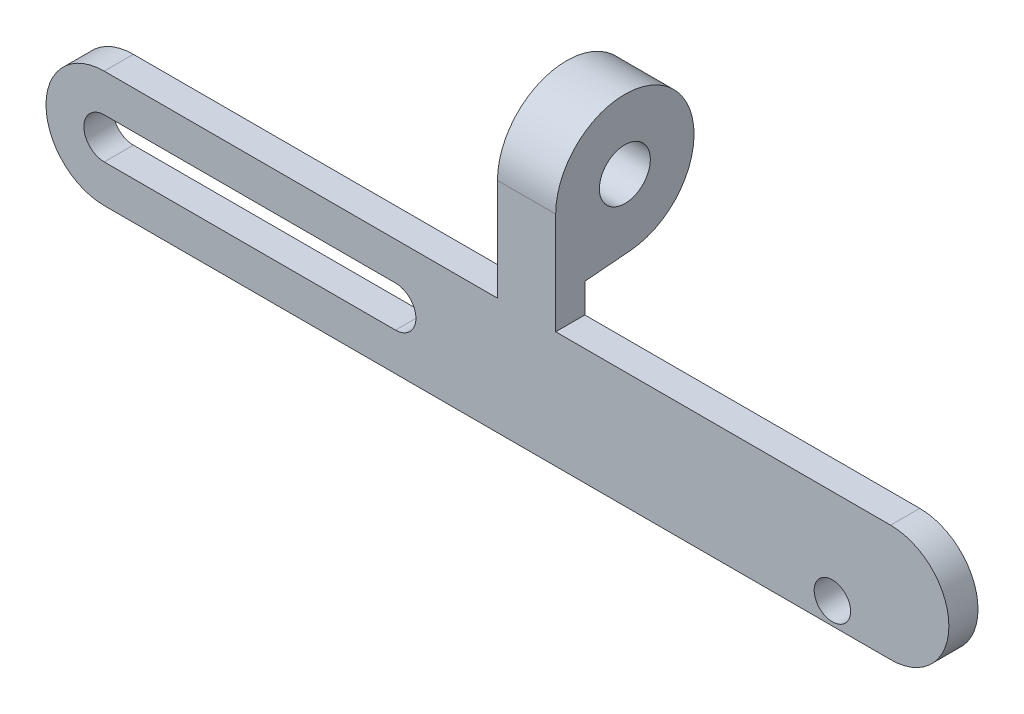
from build123d import *

# Parameters (mm, degrees)
ESBO_O1_R                = 1.25
RESSALTO_EXTRUS_O1_DEPTH = 2
ESBO_O2_R                = 0.75
RESSALTO_EXTRUS_O2_DEPTH = 5
ESBO_O3_R                = 1.75
RESSALTO_EXTRUS_O3_DEPTH = 4


with BuildPart() as part:
    # Esboço1 → Ressalto-extrusão1 (new body)
    with BuildSketch(Plane.XY):
        with BuildLine():
            Line((-27, 4), (27, 4))
            ThreePointArc((27, 4), (31, 0), (27, -4))
            Line((27, -4), (-27, -4))
            ThreePointArc((-27, -4), (-31, 0), (-27, 4))
        make_face()
        with Locations((23, -2.5)):
            Circle(ESBO_O1_R, mode=Mode.SUBTRACT)
        with BuildLine():
            Line((-27, 1.4), (-7, 1.4))
            ThreePointArc((-7, 1.4), (-5.6, 0), (-7, -1.4))
            Line((-7, -1.4), (-27, -1.4))
            ThreePointArc((-27, -1.4), (-28.4, 0), (-27, 1.4))
        make_face(mode=Mode.SUBTRACT)
    extrude(amount=RESSALTO_EXTRUS_O1_DEPTH)

    # Esboço2 → Ressalto-extrusão2 (add)
    with BuildSketch(Plane.XY.offset(2)):
        with Locations((27, -2.4)):
            Circle(ESBO_O2_R)
    extrude(amount=-RESSALTO_EXTRUS_O2_DEPTH)

    # Esboço3 → Ressalto-extrusão3 (add)
    with BuildSketch(Plane(origin=(0, 0, 0), x_dir=(0, 0, -1), z_dir=(1, 0, 0))):
        with BuildLine():
            Line((-2, 4), (-2, 11))
            ThreePointArc((-2, 11), (5.96386061, 14.497656355), (3.150989464, 6.266955795))
            Line((3.150989464, 6.266955795), (0, 6))
            Line((0, 6), (0, 4))
            Line((0, 4), (-2, 4))
        make_face()
        with Locations((2.75, 11)):
            Circle(ESBO_O3_R, mode=Mode.SUBTRACT)
    extrude(amount=RESSALTO_EXTRUS_O3_DEPTH)


solid = part.part
